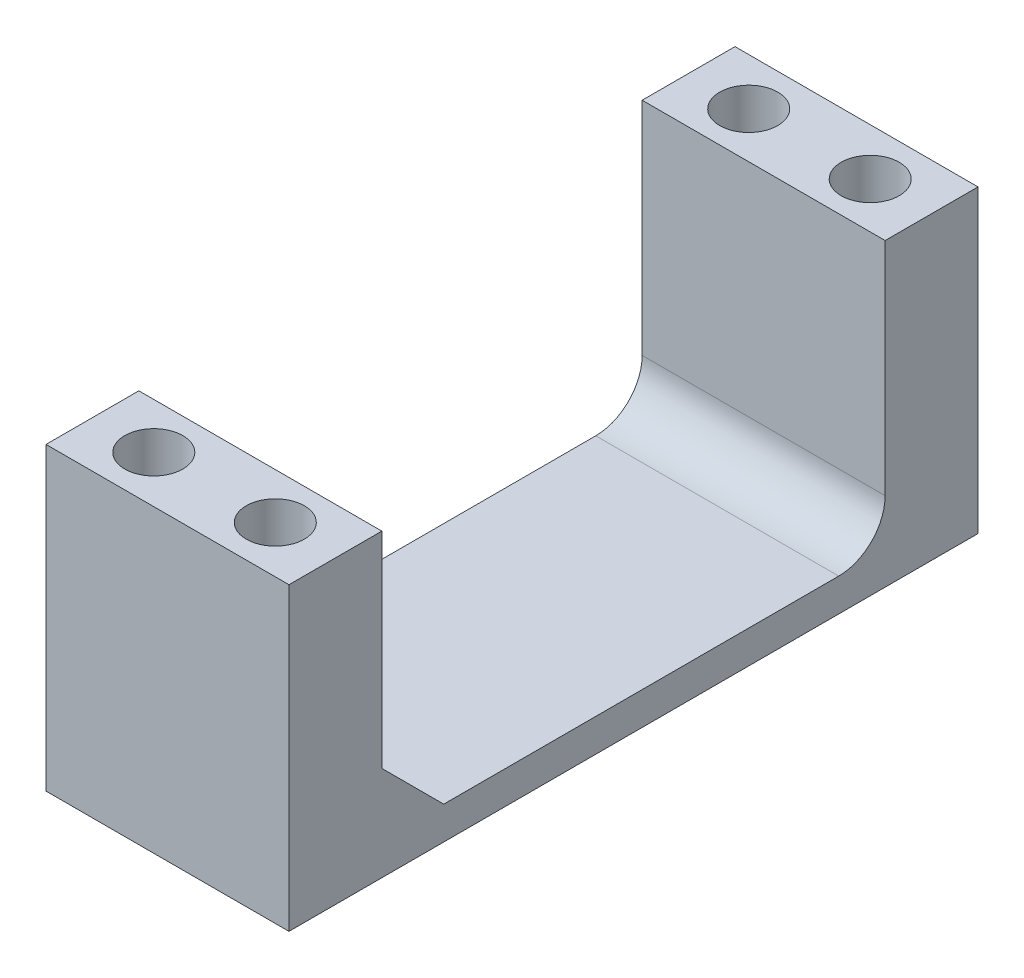
from build123d import *

# Parameters (mm, degrees)
BOSS_EXTRUDE3_START     = 44.460213
BOSS_EXTRUDE3_DEPTH     = 19.939
CHAMFER2_SIZE           = 5.08
FILLET2_R               = 3.81
SKETCH4_R               = 2.38125
CUT_EXTRUDE1_DEPTH      = 4.591914717
CUT_EXTRUDE1_DEPTH_BACK = 22.046085283


with BuildPart() as part:
    # Sketch3 → Boss-Extrude3 (new body)
    with BuildSketch(Plane(origin=(0, 0, 0), x_dir=(0, 0, -1), z_dir=(1, 0, 0)).offset(BOSS_EXTRUDE3_START)):
        Polygon((30.787104637, 3.591914717), (30.787104637, -18.352057258), (-10.513295363, -18.352057258), (-10.513295363, 3.591914717), (-18.133295363, 3.591914717), (-18.133295363, -21.046085283), (38.407104637, -21.046085283), (38.407104637, 3.591914717), align=None)
    extrude(amount=BOSS_EXTRUDE3_DEPTH)

    # Chamfer2
    chamfer2_edges = [part.edges().sort_by_distance(p)[0] for p in [
        (54.429713, -18.352057258, 10.513295363),
    ]]
    chamfer(chamfer2_edges, length=CHAMFER2_SIZE)

    # Fillet2
    fillet2_edges = [part.edges().sort_by_distance(p)[0] for p in [
        (54.429713, -18.352057258, -30.787104637),
    ]]
    fillet(fillet2_edges, radius=FILLET2_R)

    # Sketch4 → Cut-Extrude1 (cut, two sides)
    with BuildSketch(Plane(origin=(0, 0, 0), x_dir=(1, 0, 0), z_dir=(0, 1, 0))) as cut_extrude1_sk:
        with Locations((49.444963475, 34.546304637)):
            Circle(SKETCH4_R)
        with Locations((59.414463475, 34.546304637)):
            Circle(SKETCH4_R)
        with Locations((49.444963475, -14.272495363)):
            Circle(SKETCH4_R)
        with Locations((59.414463475, -14.272495363)):
            Circle(SKETCH4_R)
    extrude(amount=CUT_EXTRUDE1_DEPTH, mode=Mode.SUBTRACT)
    extrude(cut_extrude1_sk.sketch, amount=-CUT_EXTRUDE1_DEPTH_BACK, mode=Mode.SUBTRACT)


solid = part.part
